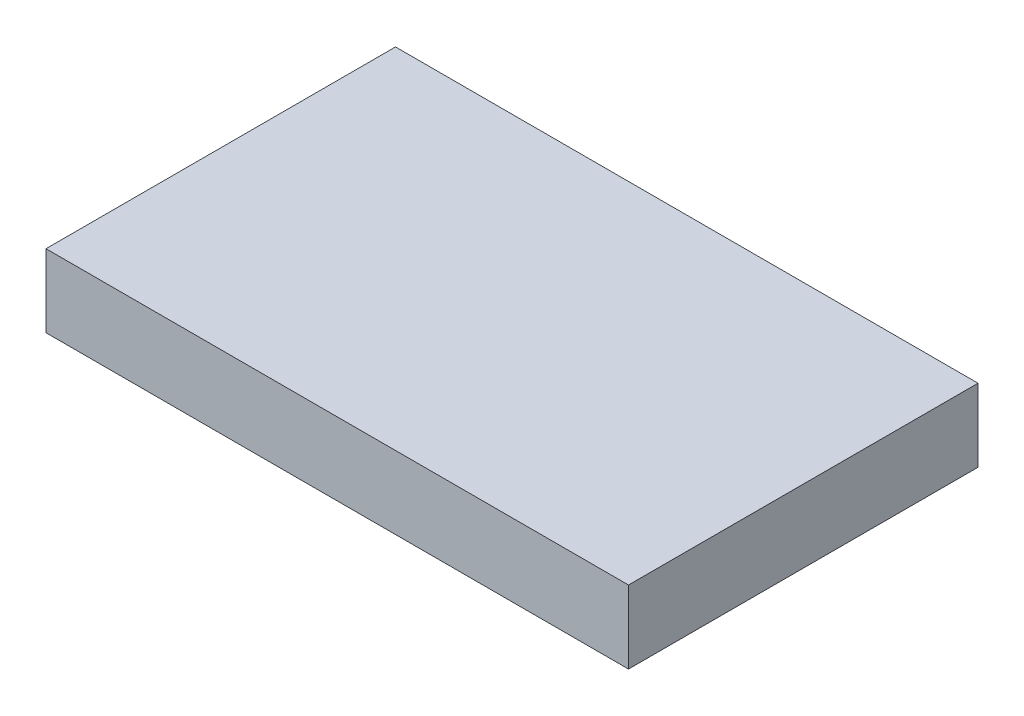
from build123d import *

# Parameters (mm, degrees)
SKETCH1_W           = 50.8
SKETCH1_H           = 30.48
BOSS_EXTRUDE1_DEPTH = 3.175


with BuildPart() as part:
    # Sketch1 → Boss-Extrude1 (new body, symmetric)
    with BuildSketch(Plane(origin=(0, 0, 0), x_dir=(1, 0, 0), z_dir=(0, 1, 0))):
        Rectangle(SKETCH1_W, SKETCH1_H)
    extrude(amount=BOSS_EXTRUDE1_DEPTH, both=True)


solid = part.part
